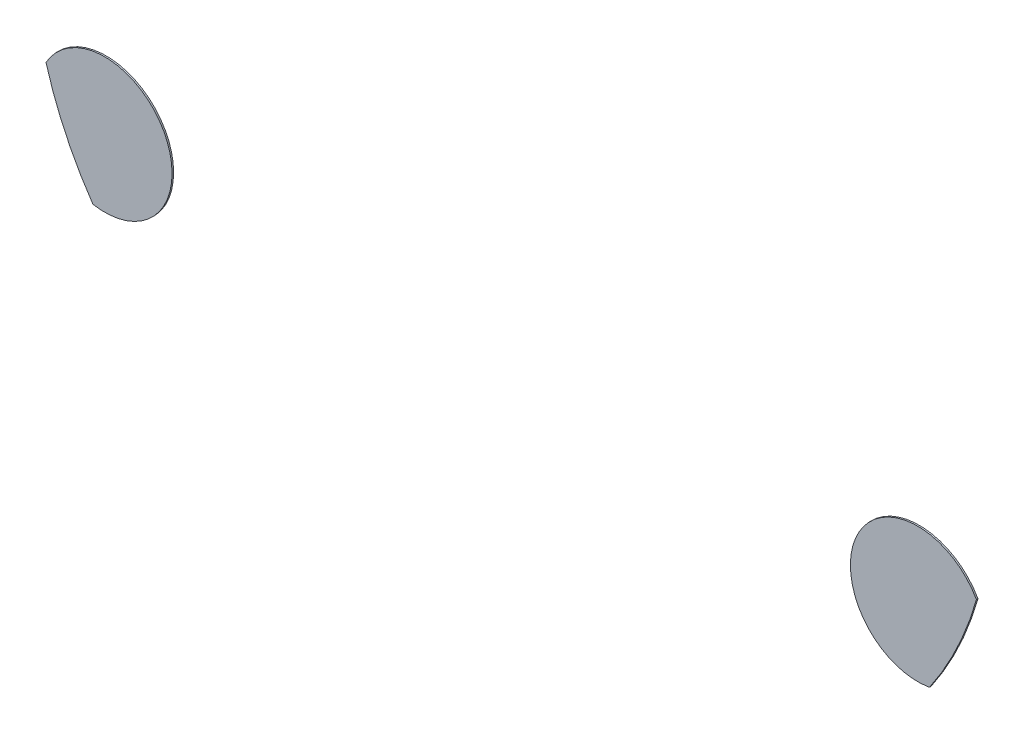
from build123d import *

# Parameters (mm, degrees)
SALIENTE_EXTRUIR1_DEPTH   = 0.1
SALIENTE_EXTRUIR1_2_DEPTH = 0.1


with BuildPart() as part:
    # Model → Saliente-Extruir1 (new body)
    with BuildSketch(Plane.XY):
        with BuildLine():
            ThreePointArc((3.890171253, 33.520517491), (5.144616973, 30.191270124), (6.918449363, 27.107272596))
            ThreePointArc((6.918449363, 27.107272596), (11.607345034, 33.242913751), (3.890171253, 33.520517491))
        make_face()
    extrude(amount=SALIENTE_EXTRUIR1_DEPTH)


with BuildPart() as body_2:
    # Model → Saliente-Extruir1 2 (new body)
    with BuildSketch(Plane.XY):
        with BuildLine():
            ThreePointArc((60.893838912, 27.107272596), (62.667671302, 30.191270124), (63.922117021, 33.520517491))
            ThreePointArc((63.922117021, 33.520517491), (56.204943241, 33.242913751), (60.893838912, 27.107272596))
        make_face()
    extrude(amount=SALIENTE_EXTRUIR1_2_DEPTH)


solid = Compound([part.part, body_2.part])
